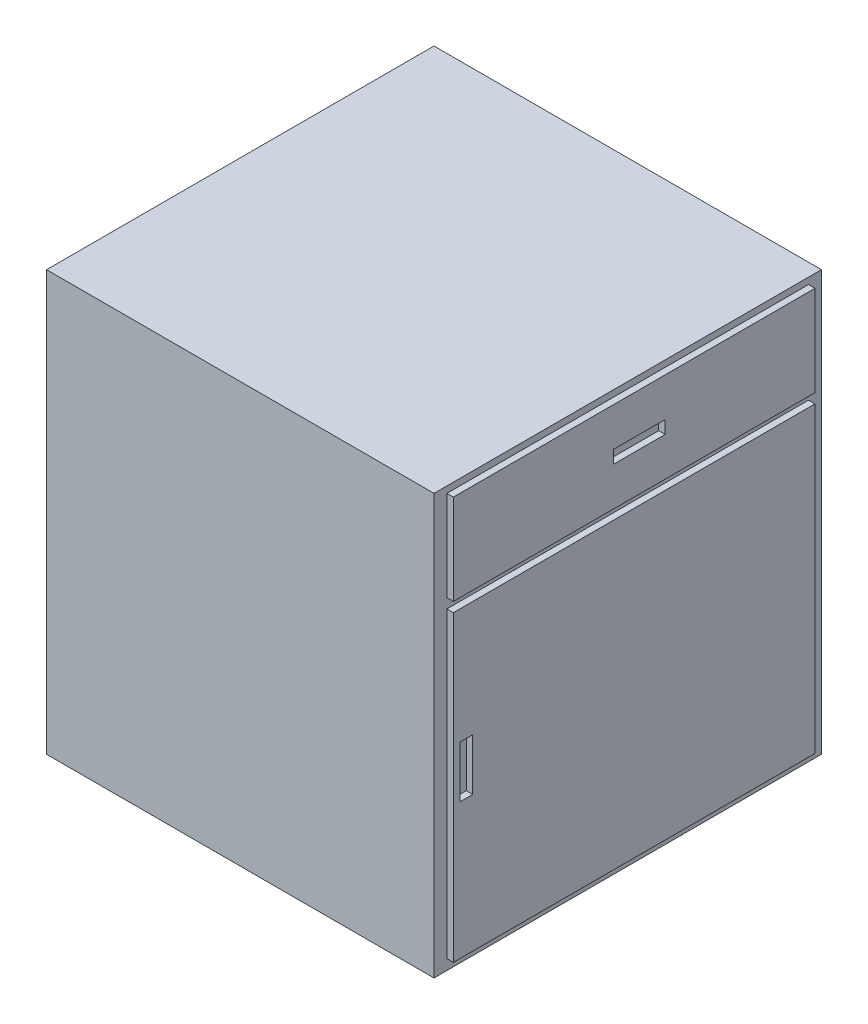
from build123d import *

# Parameters (mm, degrees)
SKETCH1_W           = 600
SKETCH1_H           = 650
BOSS_EXTRUDE1_DEPTH = 600
SKETCH2_W           = 560
SKETCH2_H           = 140
SKETCH2_W_2         = 80
SKETCH2_H_2         = 20
SKETCH2_H_3         = 468.975468976
SKETCH2_W_3         = 20
SKETCH2_H_4         = 80
BOSS_EXTRUDE2_DEPTH = 10


with BuildPart() as part:
    # Sketch1 → Boss-Extrude1 (new body)
    with BuildSketch(Plane.XY):
        with Locations((-300, -325)):
            Rectangle(SKETCH1_W, SKETCH1_H)
    extrude(amount=BOSS_EXTRUDE1_DEPTH)

    # Sketch2 → Boss-Extrude2 (add)
    with BuildSketch(Plane(origin=(0, 0, 0), x_dir=(0, 0, -1), z_dir=(1, 0, 0))):
        with Locations((-300, -79.996604702)):
            Rectangle(SKETCH2_W, SKETCH2_H)
        with Locations((-292, -79.960529666)):
            Rectangle(SKETCH2_W_2, SKETCH2_H_2, mode=Mode.SUBTRACT)
        with Locations((-300, -399.48433919)):
            Rectangle(SKETCH2_W, SKETCH2_H_3)
        with Locations((-560, -383.759018759)):
            Rectangle(SKETCH2_W_3, SKETCH2_H_4, mode=Mode.SUBTRACT)
    extrude(amount=BOSS_EXTRUDE2_DEPTH)


solid = part.part
